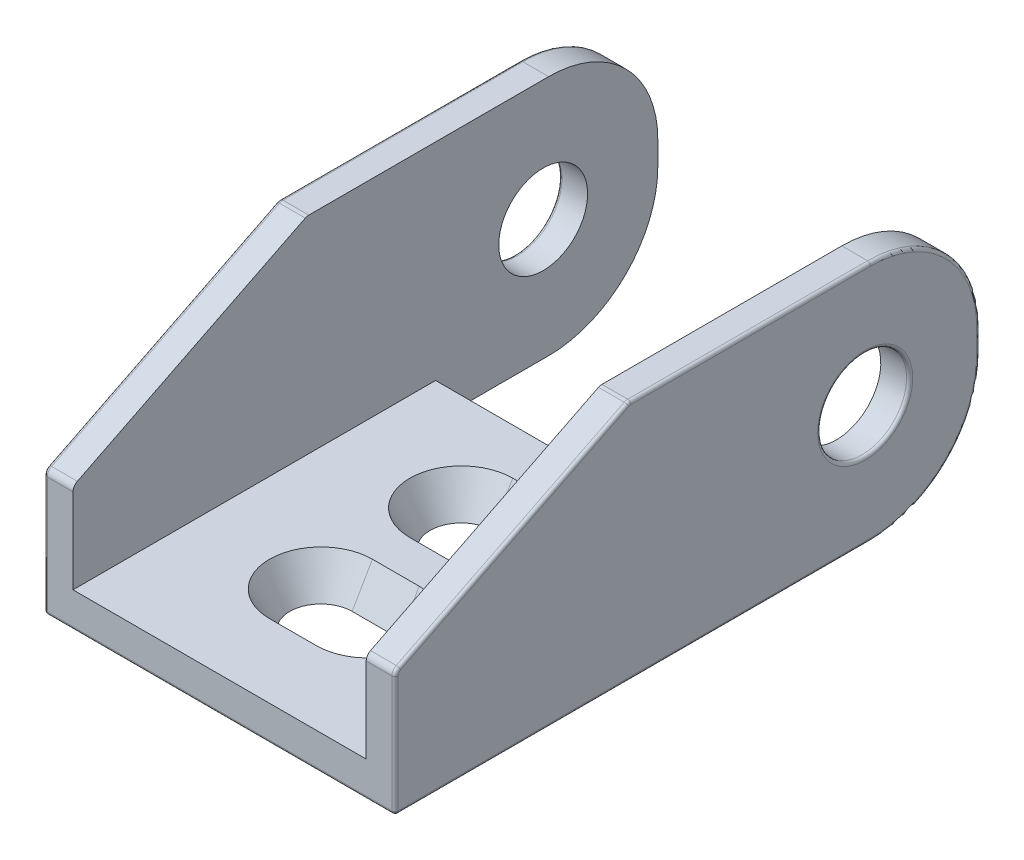
from build123d import *

# Parameters (mm, degrees)
SKETCH1_R               = 2.85
BOSS_EXTRUDE1_DEPTH     = 11.25
SKETCH2_W               = 18.8
SKETCH2_H               = 13.25
CUT_EXTRUDE1_DEPTH      = 31.15
CUT_EXTRUDE1_DEPTH_BACK = 8.35
SKETCH3_W               = 18.8
SKETCH3_H               = 12
CUT_EXTRUDE2_DEPTH      = 2.25
FILLET1_R               = 7
CUT_EXTRUDE3_DEPTH      = 2.25
CUT_EXTRUDE3_TAPER      = -30
CUT_EXTRUDE4_DEPTH      = 18.8
SKETCH6_W               = 12
SKETCH6_H               = 4
CUT_EXTRUDE5_DEPTH      = 0.8
BOSS_EXTRUDE2_DEPTH     = 0.15
FILLET2_R               = 0.5
FILLET3_R               = 0.2


with BuildPart() as part:
    # Sketch1 → Boss-Extrude1 (new body, symmetric)
    with BuildSketch(Plane(origin=(0, 0, 0), x_dir=(0, 0, -1), z_dir=(1, 0, 0))):
        Polygon((7.35, 7.75), (7.35, -7.75), (-30.15, -7.75), (-30.15, 0.25), (-15.15, 7.75), align=None)
        Circle(SKETCH1_R, mode=Mode.SUBTRACT)
    extrude(amount=BOSS_EXTRUDE1_DEPTH, both=True)

    # Sketch2 → Cut-Extrude1 (cut, two sides)
    with BuildSketch(Plane.XY) as cut_extrude1_sk:
        with Locations((0, 1.125)):
            Rectangle(SKETCH2_W, SKETCH2_H)
    extrude(amount=CUT_EXTRUDE1_DEPTH, mode=Mode.SUBTRACT)
    extrude(cut_extrude1_sk.sketch, amount=-CUT_EXTRUDE1_DEPTH_BACK, mode=Mode.SUBTRACT)

    # Sketch3 → Cut-Extrude2 (cut)
    with BuildSketch(Plane(origin=(0, -5.5, 0), x_dir=(1, 0, 0), z_dir=(0, 1, 0))):
        with Locations((0, 1.35)):
            Rectangle(SKETCH3_W, SKETCH3_H)
    extrude(amount=-CUT_EXTRUDE2_DEPTH, mode=Mode.SUBTRACT)

    # Fillet1
    fillet1_edges = [part.edges().sort_by_distance(p)[0] for p in [
        (-10.325, 7.75, -7.35),
        (-10.325, -7.75, -7.35),
        (10.325, 7.75, -7.35),
        (10.325, -7.75, -7.35),
    ]]
    fillet(fillet1_edges, radius=FILLET1_R)

    # Sketch4 → Cut-Extrude3 (cut)
    with BuildSketch(Plane.XZ.offset(7.75)):
        with BuildLine():
            ThreePointArc((-1.5, 24.15), (-3.5, 22.15), (-1.5, 20.15))
            Line((-1.5, 20.15), (1.5, 20.15))
            ThreePointArc((1.5, 20.15), (3.5, 22.15), (1.5, 24.15))
            Line((1.5, 24.15), (-1.5, 24.15))
        make_face()
        with BuildLine():
            ThreePointArc((-1.5, 15.15), (-3.5, 13.15), (-1.5, 11.15))
            Line((-1.5, 11.15), (1.5, 11.15))
            ThreePointArc((1.5, 11.15), (3.5, 13.15), (1.5, 15.15))
            Line((1.5, 15.15), (-1.5, 15.15))
        make_face()
    extrude(amount=-CUT_EXTRUDE3_DEPTH, taper=CUT_EXTRUDE3_TAPER, mode=Mode.SUBTRACT)

    # Sketch5 → Cut-Extrude4 (cut)
    with BuildSketch(Plane.ZY.offset(-9.4)):
        Polygon((4.65, -7.75), (4.65, -5.5), (6.9, -5.5), align=None)
    extrude(amount=CUT_EXTRUDE4_DEPTH, mode=Mode.SUBTRACT)

    # Sketch6 → Cut-Extrude5 (cut)
    with BuildSketch(Plane.XZ.offset(7.75)):
        with Locations((0, 17.65)):
            Rectangle(SKETCH6_W, SKETCH6_H)
    extrude(amount=-CUT_EXTRUDE5_DEPTH, mode=Mode.SUBTRACT)

    # Sketch7 → Boss-Extrude2 (add)
    with BuildSketch(Plane.XZ.offset(6.95)):
        Polygon((4.634853267, 16.398770519), (4.172613684, 16.398770519), (4.172613684, 18.898770519), (4.396972658, 18.898770519), (4.396972658, 16.655180775), (4.781588043, 16.655180775), align=None)
        with BuildLine():
            add(Edge.make_bspline(
                [(3.137357273, 17.649772121), (3.137122975, 17.609702558), (3.136667846, 17.531866855), (3.131604688, 17.418449254), (3.12319373, 17.312049047), (3.111667033, 17.212661145), (3.097639912, 17.120259877), (3.078914538, 17.035092218), (3.057619766, 16.956763845), (3.032939155, 16.885019803), (3.005091743, 16.818891915), (2.974777997, 16.757163002), (2.940815767, 16.699906803), (2.905072848, 16.646279717), (2.866298305, 16.59682143), (2.824626977, 16.551754219), (2.780425908, 16.510379699), (2.733485952, 16.473378221), (2.684254504, 16.441136368), (2.634187895, 16.411909858), (2.581858124, 16.388790883), (2.528555931, 16.369021496), (2.473851873, 16.353361469), (2.417722121, 16.342468692), (2.360116305, 16.335653939), (2.32123737, 16.334999734), (2.301519934, 16.334667954)],
                knots=[0, 0, 0, 0, 0.000120202, 0.000233494, 0.000340503, 0.000440329, 0.000533614, 0.000620743, 0.000701782, 0.00077701, 0.000848163, 0.00091692, 0.000983142, 0.00104773, 0.001110145, 0.001171458, 0.001231696, 0.001291608, 0.001350501, 0.001408145, 0.0014653, 0.001521864, 0.001578616, 0.001635778, 0.001693239, 0.001752368, 0.001752368, 0.001752368, 0.001752368], degree=3))
            add(Edge.make_bspline(
                [(2.301519934, 16.334667954), (2.281627807, 16.334943847), (2.242049475, 16.335492777), (2.183745798, 16.34321929), (2.126457671, 16.353192125), (2.071054269, 16.369186909), (2.01648802, 16.388326743), (1.964115876, 16.413581449), (1.912088825, 16.441047903), (1.862770386, 16.474554667), (1.814687013, 16.511585155), (1.769613871, 16.553624226), (1.726398771, 16.599508444), (1.686673929, 16.650261161), (1.648736794, 16.705104188), (1.614027498, 16.764497266), (1.581824151, 16.828308774), (1.551521415, 16.896242889), (1.525022473, 16.970114238), (1.501462795, 17.049462066), (1.482151653, 17.135004905), (1.466181677, 17.226266227), (1.453785937, 17.32369814), (1.444764526, 17.427103236), (1.439997495, 17.536546205), (1.439099927, 17.611373264), (1.438639325, 17.649772121)],
                knots=[0, 0, 0, 0, 5.9629e-05, 0.000118641, 0.0001762, 0.000233916, 0.000291421, 0.000349449, 0.000408163, 0.00046775, 0.000528056, 0.000590077, 0.000652438, 0.000716964, 0.000783225, 0.000852367, 0.000923141, 0.000997584, 0.001075369, 0.001158403, 0.00124575, 0.001338294, 0.001436253, 0.00154031, 0.0016496, 0.001764802, 0.001764802, 0.001764802, 0.001764802], degree=3))
            add(Edge.make_bspline(
                [(1.438639325, 17.649772121), (1.439110634, 17.688003007), (1.440031018, 17.762661074), (1.444656035, 17.871618708), (1.454027771, 17.974459548), (1.465450222, 18.071332592), (1.481919162, 18.162111212), (1.500254014, 18.247282921), (1.523641146, 18.32604743), (1.549511539, 18.399285571), (1.579392633, 18.466931912), (1.61135345, 18.530480026), (1.646580877, 18.589536035), (1.683790068, 18.644726685), (1.724266981, 18.695044134), (1.766897252, 18.741441622), (1.812407673, 18.783553731), (1.860738566, 18.821021449), (1.910523154, 18.854780616), (1.962560348, 18.883226441), (2.015632005, 18.908025396), (2.07029014, 18.927960855), (2.126186213, 18.943719914), (2.183521516, 18.954447812), (2.242057272, 18.962009629), (2.281630415, 18.962584268), (2.301519934, 18.962873083)],
                knots=[0, 0, 0, 0, 0.000114701, 0.00022399, 0.00032705, 0.000424449, 0.0005165, 0.000603737, 0.000685668, 0.000762812, 0.000836595, 0.00090737, 0.00097608, 0.001042754, 0.001106888, 0.001169616, 0.001231637, 0.001292646, 0.001352928, 0.001411882, 0.001470365, 0.001528512, 0.001586228, 0.001644372, 0.001703384, 0.001763013, 0.001763013, 0.001763013, 0.001763013], degree=3))
            add(Edge.make_bspline(
                [(2.301519934, 18.962873083), (2.321236682, 18.962538363), (2.360114263, 18.96187836), (2.417730005, 18.955106079), (2.473778372, 18.944062769), (2.528371412, 18.929066011), (2.581620839, 18.910006013), (2.633005071, 18.885762431), (2.683202523, 18.85764354), (2.731984882, 18.825653446), (2.778419573, 18.788992077), (2.822783403, 18.74845157), (2.863915177, 18.702987152), (2.902422316, 18.653324471), (2.938461804, 18.599562388), (2.972280214, 18.541867861), (3.002501645, 18.479537603), (3.030980463, 18.413050735), (3.056084759, 18.340779536), (3.078005367, 18.262182743), (3.096486434, 18.176724254), (3.111206861, 18.084399976), (3.123266174, 17.985352835), (3.131596396, 17.879424993), (3.136665315, 17.76684334), (3.137122411, 17.689507977), (3.137357273, 17.649772121)],
                knots=[0, 0, 0, 0, 5.9128e-05, 0.00011659, 0.000173751, 0.000230369, 0.00028629, 0.000343199, 0.000400597, 0.000458796, 0.000518005, 0.000577902, 0.000638877, 0.000701687, 0.000766275, 0.000832928, 0.000902135, 0.000973944, 0.00104981, 0.001131465, 0.001218594, 0.001311959, 0.001411843, 0.001517855, 0.001630646, 0.001749846, 0.001749846, 0.001749846, 0.001749846], degree=3))
        make_face()
        with BuildLine():
            add(Edge.make_bspline(
                [(2.912998299, 17.648770519), (2.912911109, 17.682162313), (2.91274189, 17.746969229), (2.908449099, 17.840978388), (2.902473972, 17.928808055), (2.894956916, 18.010423947), (2.883699065, 18.08554083), (2.870926315, 18.154470956), (2.855606281, 18.21708685), (2.837390223, 18.273935333), (2.816641457, 18.325822639), (2.794023461, 18.374127465), (2.769523284, 18.419437367), (2.742578817, 18.461588867), (2.712804025, 18.500346539), (2.68086349, 18.535894456), (2.646571489, 18.568087877), (2.599111427, 18.606294944), (2.536760098, 18.646241808), (2.457798374, 18.680599907), (2.376625879, 18.702331344), (2.321515309, 18.705087262), (2.294007914, 18.706462826)],
                knots=[0, 0, 0, 0, 0.000100165, 0.000194401, 0.000282247, 0.00036427, 0.000440194, 0.000510028, 0.000574525, 0.000633441, 0.00068896, 0.000742057, 0.000793376, 0.000843386, 0.000891966, 0.000939837, 0.000986602, 0.001032904, 0.001122514, 0.001207738, 0.001290455, 0.001372885, 0.001372885, 0.001372885, 0.001372885], degree=3))
            add(Edge.make_bspline(
                [(2.294007914, 18.706462826), (2.266342568, 18.705256645), (2.21111001, 18.702848561), (2.129992767, 18.681831751), (2.051895276, 18.647665093), (1.990261565, 18.608630495), (1.943501851, 18.571218572), (1.909986926, 18.539358086), (1.879229096, 18.503673345), (1.85005597, 18.465174398), (1.823299547, 18.42312247), (1.798968717, 18.377720674), (1.776766331, 18.328842678), (1.764117012, 18.294721437), (1.757649741, 18.277276128)],
                knots=[0, 0, 0, 0, 8.2888e-05, 0.000165483, 0.000249589, 0.000337817, 0.000383414, 0.000429108, 0.000476314, 0.000524591, 0.000573909, 0.000625669, 0.000679011, 0.000734814, 0.000734814, 0.000734814, 0.000734814], degree=3))
            add(Edge.make_bspline(
                [(1.757649741, 18.277276128), (1.750112764, 18.254969171), (1.734809469, 18.209676482), (1.715086773, 18.139416731), (1.699554345, 18.065700471), (1.685580512, 17.988968244), (1.676042615, 17.908654172), (1.668365605, 17.825006755), (1.663843686, 17.737962925), (1.66328315, 17.678823646), (1.662998299, 17.648770519)],
                knots=[0, 0, 0, 0, 7.0633e-05, 0.000143414, 0.000218756, 0.000296563, 0.000377314, 0.000461285, 0.000548541, 0.000638698, 0.000638698, 0.000638698, 0.000638698], degree=3))
            add(Edge.make_bspline(
                [(1.662998299, 17.648770519), (1.663312459, 17.618718038), (1.663927099, 17.559921688), (1.667965341, 17.473902576), (1.674454459, 17.392060188), (1.683237339, 17.314320282), (1.695294374, 17.240821223), (1.70977368, 17.171457843), (1.726748979, 17.10624881), (1.746220244, 17.045026071), (1.768163776, 16.988009273), (1.792405878, 16.935075678), (1.818271754, 16.885939791), (1.84638434, 16.840759654), (1.87634589, 16.799271639), (1.909232219, 16.762430773), (1.942954413, 16.728444851), (1.990914508, 16.690344129), (2.053192143, 16.651189346), (2.131221113, 16.616136925), (2.211977733, 16.595391957), (2.266684236, 16.59251509), (2.294007914, 16.591078211)],
                knots=[0, 0, 0, 0, 9.0157e-05, 0.000176388, 0.000258278, 0.000336423, 0.000411016, 0.000481636, 0.00054893, 0.000613074, 0.00067427, 0.000732088, 0.000787648, 0.000840732, 0.000891617, 0.000940943, 0.000988751, 0.001035052, 0.001124395, 0.001208702, 0.00129081, 0.001372742, 0.001372742, 0.001372742, 0.001372742], degree=3))
            add(Edge.make_bspline(
                [(2.294007914, 16.591078211), (2.3216637, 16.59251679), (2.377025654, 16.595396568), (2.45862708, 16.616063734), (2.537123167, 16.650940042), (2.599269563, 16.690392547), (2.646554477, 16.728296884), (2.680203267, 16.760647434), (2.711958943, 16.795862904), (2.741591098, 16.834444848), (2.768371168, 16.876515973), (2.793169123, 16.921497405), (2.815606666, 16.969730475), (2.836433751, 17.021589104), (2.854456526, 17.078530999), (2.870661101, 17.141134405), (2.883168596, 17.210512815), (2.894274151, 17.285982445), (2.902668689, 17.367695373), (2.908407455, 17.455732954), (2.912754928, 17.550069823), (2.912915551, 17.61521134), (2.912998299, 17.648770519)],
                knots=[0, 0, 0, 0, 8.2929e-05, 0.000166009, 0.000250775, 0.000339694, 0.000385995, 0.000432397, 0.000479561, 0.000528141, 0.000578151, 0.000629031, 0.000682128, 0.000737647, 0.000796563, 0.000861181, 0.000931508, 0.001007927, 0.001090001, 0.001177847, 0.001272583, 0.001373249, 0.001373249, 0.001373249, 0.001373249], degree=3))
        make_face(mode=Mode.SUBTRACT)
        Polygon((1.060434196, 16.398770519), (0.801519934, 16.398770519), (0.146972658, 17.421406737), (-0.507574618, 16.398770519), (-0.766488881, 16.398770519), (0.017265126, 17.623730454), (-0.798540163, 18.898770519), (-0.5396259, 18.898770519), (0.146972658, 17.826054172), (0.833571216, 18.898770519), (1.092485478, 18.898770519), (0.276179389, 17.623730454), align=None)
        Polygon((-1.643992887, 16.398770519), (-2.10623247, 16.398770519), (-2.10623247, 18.898770519), (-1.881873496, 18.898770519), (-1.881873496, 16.655180775), (-1.497258111, 16.655180775), align=None)
        with BuildLine():
            Line((-4.712001701, 16.398770519), (-4.712001701, 16.655180775))
            Line((-4.712001701, 16.655180775), (-3.861641124, 16.655180775))
            Line((-3.861641124, 16.655180775), (-3.726925579, 17.312732858))
            add(Edge.make_bspline(
                [(-3.726925579, 17.312732858), (-3.753394061, 17.305425521), (-3.804672558, 17.291268712), (-3.880358173, 17.275550304), (-3.952209747, 17.266074987), (-3.998835011, 17.264781194), (-4.021396733, 17.264155134)],
                knots=[0, 0, 0, 0, 8.2359e-05, 0.000159557, 0.000231736, 0.000299411, 0.000299411, 0.000299411, 0.000299411], degree=3))
            add(Edge.make_bspline(
                [(-4.021396733, 17.264155134), (-4.049318718, 17.264739577), (-4.104220317, 17.265888738), (-4.184424762, 17.277573034), (-4.261367886, 17.294508212), (-4.333942966, 17.320557749), (-4.403320061, 17.352573898), (-4.468558588, 17.392375549), (-4.529964997, 17.439395549), (-4.587405063, 17.49266934), (-4.6391893, 17.55198387), (-4.684368266, 17.615811603), (-4.722985448, 17.683440315), (-4.753790522, 17.755492077), (-4.778766702, 17.831287877), (-4.79528098, 17.911463724), (-4.806299237, 17.995352551), (-4.807528634, 18.052713332), (-4.808155547, 18.081963628)],
                knots=[0, 0, 0, 0, 8.3707e-05, 0.000164589, 0.000242703, 0.00031968, 0.000395407, 0.00047159, 0.000548415, 0.000627081, 0.000706228, 0.000784181, 0.00086133, 0.000939386, 0.001018889, 0.001100317, 0.001184609, 0.00127232, 0.00127232, 0.00127232, 0.00127232], degree=3))
            add(Edge.make_bspline(
                [(-4.808155547, 18.081963628), (-4.80768013, 18.102336542), (-4.806735719, 18.142807047), (-4.801942064, 18.202911522), (-4.792682417, 18.261736632), (-4.780383773, 18.31916586), (-4.764030044, 18.375284909), (-4.744690948, 18.430226188), (-4.721543355, 18.483898803), (-4.695128784, 18.536035684), (-4.665075928, 18.585610644), (-4.633002779, 18.633201339), (-4.598054176, 18.677427113), (-4.560841922, 18.719027209), (-4.520651504, 18.756805134), (-4.478469199, 18.79233681), (-4.433351726, 18.824115104), (-4.386094471, 18.853342016), (-4.336730583, 18.879511171), (-4.284758617, 18.901340789), (-4.231319737, 18.920474675), (-4.175937582, 18.936034443), (-4.118719462, 18.948106577), (-4.059468336, 18.956327535), (-3.998481519, 18.962308998), (-3.957142309, 18.962683772), (-3.936260515, 18.962873083)],
                knots=[0, 0, 0, 0, 6.1131e-05, 0.000121435, 0.000180718, 0.000239655, 0.000297508, 0.000355956, 0.000414284, 0.000472741, 0.000531144, 0.000588094, 0.0006448, 0.000700115, 0.000755376, 0.000810135, 0.000865442, 0.000920757, 0.00097676, 0.001032852, 0.001089716, 0.00114695, 0.001205293, 0.001264998, 0.001326343, 0.001388961, 0.001388961, 0.001388961, 0.001388961], degree=3))
            add(Edge.make_bspline(
                [(-3.936260515, 18.962873083), (-3.911351052, 18.962378256), (-3.862344627, 18.961404744), (-3.790534725, 18.951268221), (-3.721487544, 18.936651218), (-3.655489455, 18.915006959), (-3.592850827, 18.886624), (-3.532663026, 18.85311768), (-3.476027786, 18.81267688), (-3.422543309, 18.766751384), (-3.373480329, 18.715814251), (-3.328312328, 18.661660414), (-3.289202499, 18.603088761), (-3.255219914, 18.541076452), (-3.22631172, 18.475461822), (-3.203581497, 18.406092575), (-3.185241249, 18.333305672), (-3.177481465, 18.283196185), (-3.173540163, 18.257744878)],
                knots=[0, 0, 0, 0, 7.468e-05, 0.000146924, 0.000217159, 0.000286208, 0.000354803, 0.000423195, 0.000492532, 0.000563202, 0.000634388, 0.000704473, 0.000774478, 0.000845302, 0.00091639, 0.000989238, 0.001064059, 0.001141287, 0.001141287, 0.001141287, 0.001141287], degree=3))
            Line((-3.173540163, 18.257744878), (-3.397899137, 18.257744878))
            add(Edge.make_bspline(
                [(-3.397899137, 18.257744878), (-3.403412604, 18.281589985), (-3.414009794, 18.327421607), (-3.43739185, 18.391737464), (-3.465528188, 18.449289014), (-3.500536536, 18.49971433), (-3.540302268, 18.544710734), (-3.586198362, 18.584724822), (-3.637834792, 18.620389162), (-3.695223095, 18.650360057), (-3.755922166, 18.6755692), (-3.819079497, 18.693568257), (-3.883798277, 18.704461357), (-3.927371506, 18.705793159), (-3.949281349, 18.706462826)],
                knots=[0, 0, 0, 0, 7.3364e-05, 0.000141009, 0.000204839, 0.000264987, 0.000324585, 0.000384558, 0.000447208, 0.0005124, 0.00057843, 0.000644056, 0.000709016, 0.000774714, 0.000774714, 0.000774714, 0.000774714], degree=3))
            add(Edge.make_bspline(
                [(-3.949281349, 18.706462826), (-3.970678422, 18.705871651), (-4.012809435, 18.704707622), (-4.074843606, 18.695892973), (-4.134560216, 18.68196081), (-4.19206527, 18.662442647), (-4.2470762, 18.636621263), (-4.299515226, 18.60490118), (-4.350129388, 18.568073786), (-4.397586597, 18.52598142), (-4.441041055, 18.479569262), (-4.479438884, 18.42994392), (-4.511422236, 18.377002957), (-4.538375213, 18.321665086), (-4.558841844, 18.263323234), (-4.573442548, 18.202250973), (-4.58201616, 18.138297413), (-4.583195574, 18.094676478), (-4.583796573, 18.072448403)],
                knots=[0, 0, 0, 0, 6.4173e-05, 0.000126357, 0.00018758, 0.00024792, 0.000308187, 0.00036951, 0.000431514, 0.000495728, 0.000559505, 0.000622009, 0.000683591, 0.00074474, 0.000806355, 0.000868668, 0.000932837, 0.000999512, 0.000999512, 0.000999512, 0.000999512], degree=3))
            add(Edge.make_bspline(
                [(-4.583796573, 18.072448403), (-4.583416699, 18.052379762), (-4.582675855, 18.013241198), (-4.573914423, 17.956033342), (-4.562113465, 17.901425289), (-4.543501229, 17.849927265), (-4.520894038, 17.801001631), (-4.491437803, 17.755857281), (-4.458872024, 17.712286839), (-4.419872279, 17.67317082), (-4.377644542, 17.636766866), (-4.330848586, 17.605891193), (-4.280821742, 17.579621746), (-4.227447425, 17.558101792), (-4.170666386, 17.540958629), (-4.11044624, 17.529110977), (-4.046773768, 17.522021465), (-4.003219733, 17.521059741), (-3.980831829, 17.52056539)],
                knots=[0, 0, 0, 0, 6.0148e-05, 0.000117303, 0.000173308, 0.000227478, 0.000281241, 0.000334592, 0.000388883, 0.00044413, 0.000499917, 0.000555893, 0.000611895, 0.000669182, 0.000728278, 0.000789565, 0.000853054, 0.000920208, 0.000920208, 0.000920208, 0.000920208], degree=3))
            add(Edge.make_bspline(
                [(-3.980831829, 17.52056539), (-3.961285741, 17.520966016), (-3.921271865, 17.521786159), (-3.859750599, 17.528240511), (-3.795382313, 17.538169911), (-3.72791711, 17.552481345), (-3.657540135, 17.570400246), (-3.584134351, 17.592778707), (-3.507697985, 17.618555872), (-3.456250837, 17.638549519), (-3.429950419, 17.648770519)],
                knots=[0, 0, 0, 0, 5.8628e-05, 0.000120021, 0.000185396, 0.000253953, 0.000326831, 0.000403196, 0.000484123, 0.000568763, 0.000568763, 0.000568763, 0.000568763], degree=3))
            Line((-3.429950419, 17.648770519), (-3.686360675, 16.398770519))
            Line((-3.686360675, 16.398770519), (-4.712001701, 16.398770519))
        make_face()
    extrude(amount=BOSS_EXTRUDE2_DEPTH)

    # Fillet2
    fillet2_edges = [part.edges().sort_by_distance(p)[0] for p in [
        (-10.325, 0.25, 30.15),
        (-10.325, 7.75, 15.15),
        (10.325, 0.25, 30.15),
        (10.325, 7.75, 15.15),
    ]]
    fillet(fillet2_edges, radius=FILLET2_R)

    # Fillet3
    fillet3_edges = [part.edges().sort_by_distance(p)[0] for p in [
        (11.25, -7.75, 14.9),
        (-11.25, 0, 2.85),
        (11.25, 0, 2.85),
        (-11.25, -3.904508497, 30.15),
        (11.25, -3.904508497, 30.15),
        (11.25, 4.042705098, 22.564589803),
        (11.25, 7.736624495, 15.146842472),
        (11.25, 0.203848562, 30.075325404),
        (-11.25, 4.042705098, 22.564589803),
        (-11.25, 7.736624495, 15.146842472),
        (-11.25, 0.203848562, 30.075325404),
        (-11.25, -7.75, 14.9),
        (11.25, 7.75, 7.340983006),
        (11.25, 0, -7.35),
        (11.25, -5.699747468, -5.299747468),
        (11.25, 5.699747468, -5.299747468),
        (-11.25, 7.75, 7.340983006),
        (-11.25, 0, -7.35),
        (-11.25, -5.699747468, -5.299747468),
        (-11.25, 5.699747468, -5.299747468),
        (0, -7.75, 30.15),
    ]]
    fillet(fillet3_edges, radius=FILLET3_R)


solid = part.part
